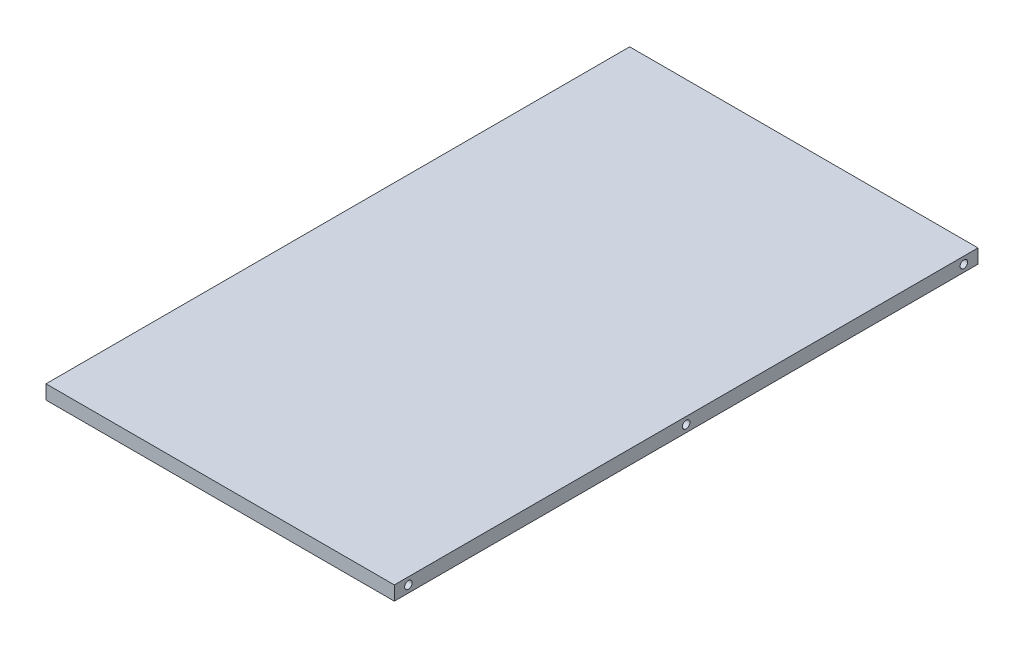
from build123d import *

# Parameters (mm, degrees)
SKETCH1_W               = 370
SKETCH1_H               = 620
BOSS_EXTRUDE1_DEPTH     = 15
SKETCH2_R               = 2.5
CUT_EXTRUDE1_DEPTH      = 2
SKETCH5_R               = 4
CUT_EXTRUDE2_DEPTH      = 10
LPATTERN1_COUNT         = 3
LPATTERN1_PITCH         = 295
MIRROR1_COPY_1_SKETCH_R = 4
MIRROR1_COPY_1_DEPTH    = 10
MIRROR1_COPY_2_SKETCH_R = 4
MIRROR1_COPY_2_DEPTH    = 10
SKETCH6_R               = 4
CUT_EXTRUDE4_DEPTH      = 10
LPATTERN2_COUNT         = 3
LPATTERN2_PITCH         = 170


with BuildPart() as part:
    # Sketch1 → Boss-Extrude1 (new body)
    with BuildSketch(Plane(origin=(0, 0, 0), x_dir=(1, 0, 0), z_dir=(0, 1, 0))):
        Rectangle(SKETCH1_W, SKETCH1_H)
    extrude(amount=BOSS_EXTRUDE1_DEPTH)

    # Sketch2 → Cut-Extrude1 (cut)
    with BuildSketch(Plane.XZ):
        with Locations((160, 285)):
            Circle(SKETCH2_R)
        with Locations((-160, 285)):
            Circle(SKETCH2_R)
        with Locations((-160, -285)):
            Circle(SKETCH2_R)
        with Locations((160, -285)):
            Circle(SKETCH2_R)
    extrude(amount=-CUT_EXTRUDE1_DEPTH, mode=Mode.SUBTRACT)

    # Sketch5 → Cut-Extrude2 (cut)
    with BuildSketch(Plane.ZY.offset(185)):
        with Locations((-295, 7.5)):
            Circle(SKETCH5_R)
    cut_extrude2 = extrude(amount=-CUT_EXTRUDE2_DEPTH, mode=Mode.SUBTRACT)

    # LPattern1: Cut-Extrude2 ×3
    with Locations(*[(0, 0, i * LPATTERN1_PITCH) for i in range(1, LPATTERN1_COUNT)]):
        add(cut_extrude2, mode=Mode.SUBTRACT)

    # Mirror1: Cut-Extrude2 across plane
    add(cut_extrude2.mirror(Plane(origin=(0, 0, 0), x_dir=(0, 0, 1), z_dir=(1, 0, 0))), mode=Mode.SUBTRACT)

    # Mirror1 copy 1 sketch → Mirror1 copy 1 (cut)
    with BuildSketch(Plane(origin=(185, 0, 295), x_dir=(0, 0, 1), z_dir=(1, 0, 0))):
        with Locations((-295, -7.5)):
            Circle(MIRROR1_COPY_1_SKETCH_R)
    extrude(amount=-MIRROR1_COPY_1_DEPTH, mode=Mode.SUBTRACT)

    # Mirror1 copy 2 sketch → Mirror1 copy 2 (cut)
    with BuildSketch(Plane(origin=(185, 0, 590), x_dir=(0, 0, 1), z_dir=(1, 0, 0))):
        with Locations((-295, -7.5)):
            Circle(MIRROR1_COPY_2_SKETCH_R)
    extrude(amount=-MIRROR1_COPY_2_DEPTH, mode=Mode.SUBTRACT)

    # Sketch6 → Cut-Extrude4 (cut)
    with BuildSketch(Plane(origin=(0, 0, -310), x_dir=(-1, 0, 0), z_dir=(0, 0, -1))):
        with Locations((-170, 7.5)):
            Circle(SKETCH6_R)
    cut_extrude4 = extrude(amount=-CUT_EXTRUDE4_DEPTH, mode=Mode.SUBTRACT)

    # LPattern2: Cut-Extrude4 ×3
    with Locations(*[(-i * LPATTERN2_PITCH, 0, 0) for i in range(1, LPATTERN2_COUNT)]):
        add(cut_extrude4, mode=Mode.SUBTRACT)


solid = part.part
